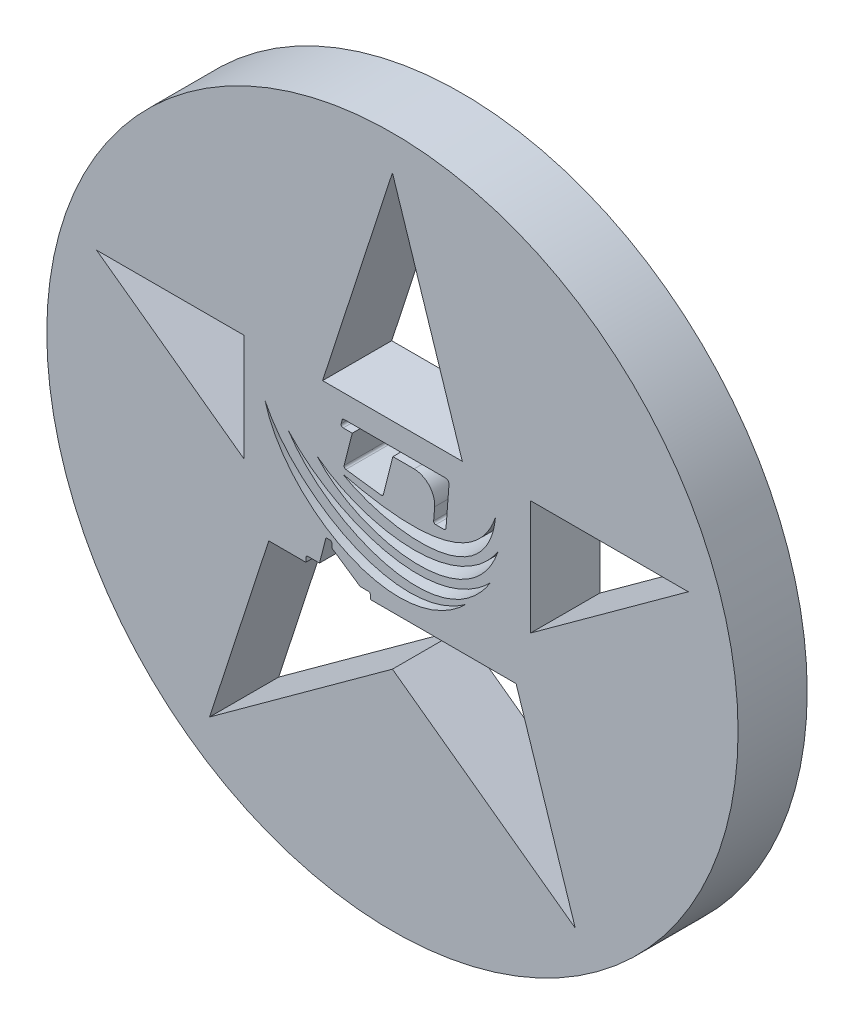
from build123d import *

# Parameters (mm, degrees)
SKETCH_1_R      = 5
EXTRUDE_1_DEPTH = 1


with BuildPart() as part:
    # 草图1 → 凸台-拉伸1 (new body)
    with BuildSketch(Plane.XY):
        Circle(SKETCH_1_R)
        with BuildLine():
            Line((-0.318380039, -1.005793851), (1.720384349, -1.005793851))
            Line((1.720384349, -1.005793851), (1.788940866, -1.005793851))
            Line((1.788940866, -1.005793851), (2.645033635, -3.640576475))
            Line((2.645033635, -3.640576475), (0, -1.718847051))
            Line((0, -1.718847051), (-2.645033635, -3.640576475))
            Line((-2.645033635, -3.640576475), (-1.788940866, -1.005793851))
            Line((-1.788940866, -1.005793851), (-1.252770646, -1.005793851))
            Line((-1.252770646, -1.005793851), (-1.252770646, -0.94707964))
            ThreePointArc((-1.252770646, -0.94707964), (-1.24398385, -0.925866437), (-1.222770646, -0.91707964))
            Line((-1.222770646, -0.91707964), (-1.054612311, -0.91707964))
            Line((-1.054612311, -0.91707964), (-0.9619207, -0.552326205))
            Line((-0.9619207, -0.552326205), (-0.904349803, -0.552326205))
            ThreePointArc((-0.904349803, -0.552326205), (-0.8831366, -0.561113001), (-0.874349803, -0.582326205))
            Line((-0.874349803, -0.582326205), (-0.874349803, -0.641189165))
            Line((-0.874349803, -0.641189165), (-0.466949327, -0.91707964))
            Line((-0.466949327, -0.91707964), (-0.348380039, -0.91707964))
            ThreePointArc((-0.348380039, -0.91707964), (-0.327166836, -0.925866437), (-0.318380039, -0.94707964))
            Line((-0.318380039, -0.94707964), (-0.318380039, -1.005793851))
        make_face(mode=Mode.SUBTRACT)
        with BuildLine():
            add(Edge.make_bspline(
                [(-1.842127605, 0.722748563), (-1.53406941, -0.398381027), (0.099478664, -1.328305568), (1.067230007, -0.372749727)],
                knots=[0, 0, 0, 0, 1, 1, 1, 1], degree=3))
            add(Edge.make_bspline(
                [(-1.842127605, 0.722748563), (-1.393572664, -0.207863674), (0.098677528, -1.088124965), (1.067230007, -0.372749727)],
                knots=[0, 0, 0, 0, 1, 1, 1, 1], degree=3))
        make_face(mode=Mode.SUBTRACT)
        with BuildLine():
            add(Edge.make_bspline(
                [(-1.502914254, 0.514806758), (-0.935681631, -0.359051857), (0.725669726, -1.040375739), (1.416769627, 0.071599659)],
                knots=[0, 0, 0, 0, 1, 1, 1, 1], degree=3))
            add(Edge.make_bspline(
                [(-1.502914254, 0.514806758), (-0.839650751, -0.216239781), (0.600989178, -0.75455265), (1.416769627, 0.071599659)],
                knots=[0, 0, 0, 0, 1, 1, 1, 1], degree=3))
        make_face(mode=Mode.SUBTRACT)
        with BuildLine():
            add(Edge.make_bspline(
                [(-1.089784914, 0.404626073), (-0.465343338, -0.314626601), (1.155887368, -0.588128356), (1.526429115, 0.514806758)],
                knots=[0, 0, 0, 0, 1, 1, 1, 1], degree=3))
            add(Edge.make_bspline(
                [(-1.089784914, 0.404626073), (-0.382266231, -0.142810276), (0.950686118, -0.345522278), (1.526429115, 0.514806758)],
                knots=[0, 0, 0, 0, 1, 1, 1, 1], degree=3))
        make_face(mode=Mode.SUBTRACT)
        Polygon((-4.279754323, 1.390576475), (-2.15, 1.390576475), (-2.15, -0.066596805), (-2.15, -0.156780615), align=None, mode=Mode.SUBTRACT)
        Polygon((-1.010312947, 1.390576475), (0, 4.5), (1.010312947, 1.390576475), align=None, mode=Mode.SUBTRACT)
        with BuildLine():
            add(Edge.make_bspline(
                [(-0.725576796, 0.369276137), (-0.035664287, -0.02834489), (1.378252258, -0.188638059), (1.489870248, 0.924289378)],
                knots=[0, 0, 0, 0, 1, 1, 1, 1], degree=3))
            add(Edge.make_bspline(
                [(-0.725576796, 0.369276137), (-0.039042271, 0.197569955), (1.170700763, -0.001897128), (1.489870248, 0.924289378)],
                knots=[0, 0, 0, 0, 1, 1, 1, 1], degree=3))
        make_face(mode=Mode.SUBTRACT)
        with BuildLine():
            ThreePointArc((-0.712399817, 0.947220378), (-0.736081707, 0.958803862), (-0.741475678, 0.984609173))
            Line((-0.741475678, 0.984609173), (-0.7280269, 1.03753185))
            ThreePointArc((-0.7280269, 1.03753185), (-0.717367555, 1.053824945), (-0.698951039, 1.060143055))
            Line((-0.698951039, 1.060143055), (0.76839361, 1.060143055))
            ThreePointArc((0.76839361, 1.060143055), (0.805059277, 1.044137597), (0.818250912, 1.00636821))
            Line((0.818250912, 1.00636821), (0.774791122, 0.432361166))
            ThreePointArc((0.774791122, 0.432361166), (0.765273466, 0.412626673), (0.744876741, 0.404626073))
            Line((0.744876741, 0.404626073), (0.626290225, 0.404626073))
            ThreePointArc((0.626290225, 0.404626073), (0.604290825, 0.414229348), (0.596375844, 0.43689098))
            Line((0.596375844, 0.43689098), (0.610235616, 0.61994771))
            ThreePointArc((0.610235616, 0.61994771), (0.53231079, 0.847272593), (0.313771729, 0.947220378))
            Line((0.313771729, 0.947220378), (0.006808985, 0.947220378))
            Line((0.006808985, 0.947220378), (-0.131834864, 0.401638961))
            ThreePointArc((-0.131834864, 0.401638961), (-0.144081452, 0.38419279), (-0.164823975, 0.379284077))
            Line((-0.164823975, 0.379284077), (-0.673570673, 0.446217721))
            ThreePointArc((-0.673570673, 0.446217721), (-0.694492389, 0.459132127), (-0.698733285, 0.483350196))
            Line((-0.698733285, 0.483350196), (-0.580853999, 0.947220378))
            Line((-0.580853999, 0.947220378), (-0.712399817, 0.947220378))
        make_face(mode=Mode.SUBTRACT)
        Polygon((4.279754323, 1.390576475), (2, -0.265761995), (2, -0.022653284), (2, 1.390576475), align=None, mode=Mode.SUBTRACT)
    extrude(amount=EXTRUDE_1_DEPTH)


solid = part.part
